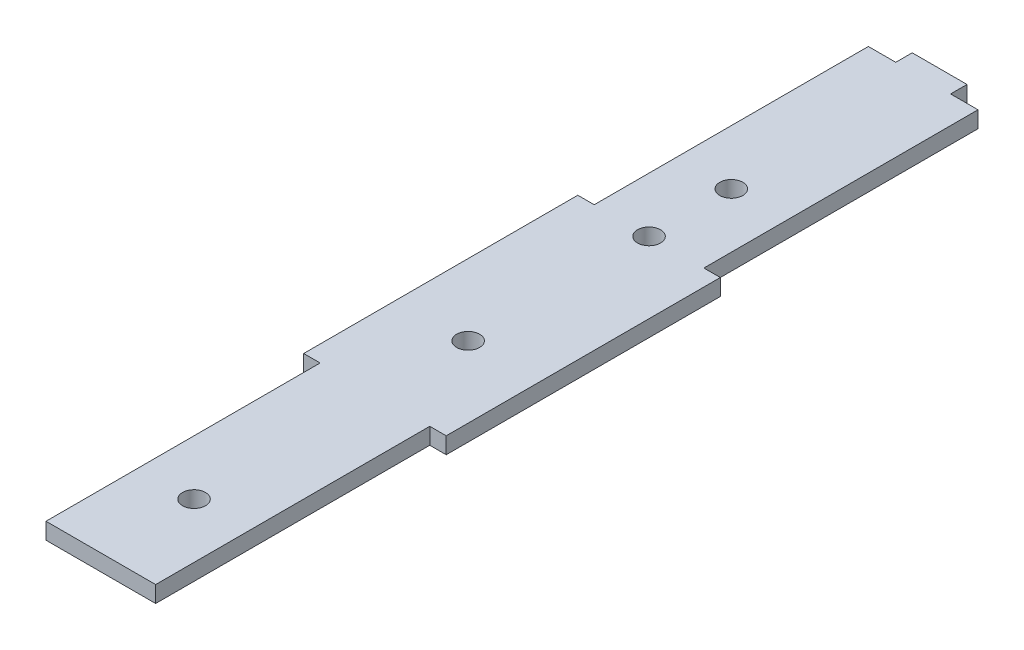
from build123d import *

# Parameters (mm, degrees)
BOSS_EXTRUDE1_DEPTH = 3
SKETCH2_R           = 2.1
CUT_EXTRUDE1_DEPTH  = 4


with BuildPart() as part:
    # Sketch1 → Boss-Extrude1 (new body)
    with BuildSketch(Plane(origin=(0, 0, 0), x_dir=(1, 0, 0), z_dir=(0, 1, 0))):
        Polygon((15, 0), (20, 0), (20, -50), (23, -50), (23, -100), (20, -100), (20, -150), (0, -150), (0, -100), (-3, -100), (-3, -50), (0, -50), (0, 0), (5, 0), (5, 3), (15, 3), align=None)
    extrude(amount=BOSS_EXTRUDE1_DEPTH)

    # Sketch2 → Cut-Extrude1 (cut, through all)
    with BuildSketch(Plane(origin=(0, 3, 0), x_dir=(1, 0, 0), z_dir=(0, 1, 0))):
        with Locations((10, -35)):
            Circle(SKETCH2_R)
        with Locations((10, -50)):
            Circle(SKETCH2_R)
        with Locations((10, -83)):
            Circle(SKETCH2_R)
        with Locations((10, -133)):
            Circle(SKETCH2_R)
    extrude(amount=-CUT_EXTRUDE1_DEPTH, mode=Mode.SUBTRACT)


solid = part.part
